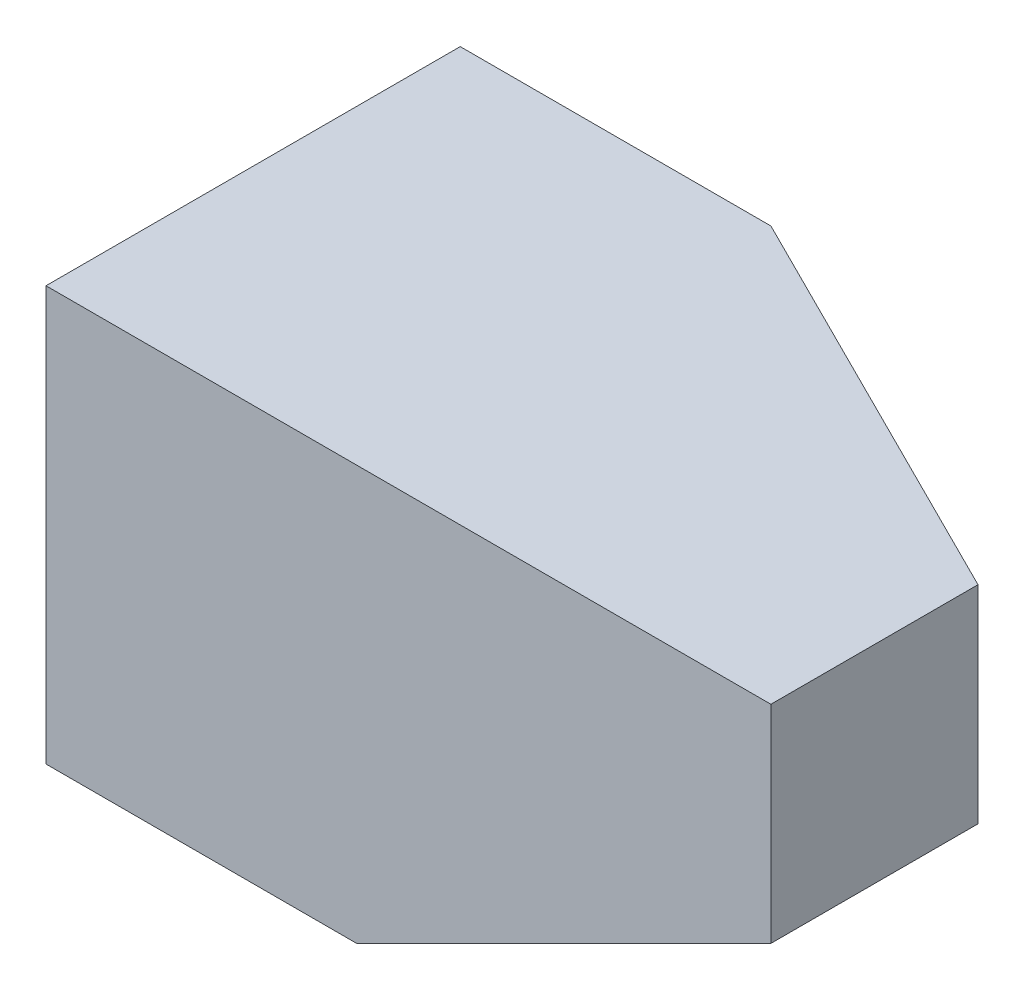
from build123d import *

# Parameters (mm, degrees)
SKETCH_1_W          = 70
SKETCH_1_H          = 40
EXTRUDE_1_DEPTH     = 40
CUT_EXTRUDE_1_DEPTH = 41
SKETCH_3_W          = 40
SKETCH_3_H          = 20
CUT_EXTRUDE_2_DEPTH = 20
CUT_EXTRUDE_3_DEPTH = 20
CUT_EXTRUDE_4_DEPTH = 31


with BuildPart() as part:
    # 草圖1 → 填料-伸長1 (new body)
    with BuildSketch(Plane(origin=(0, 0, 0), x_dir=(1, 0, 0), z_dir=(0, 1, 0))):
        with Locations((5, 0)):
            Rectangle(SKETCH_1_W, SKETCH_1_H)
    extrude(amount=EXTRUDE_1_DEPTH)

    # 草圖2 → 除料-伸長1 (cut, through all)
    with BuildSketch(Plane.XZ):
        Polygon((40, 0), (0, -20), (40, -20), align=None)
    extrude(amount=-CUT_EXTRUDE_1_DEPTH, mode=Mode.SUBTRACT)

    # 草圖3 → 除料-伸長2 (cut)
    with BuildSketch(Plane.XY):
        with Locations((20, 10)):
            Rectangle(SKETCH_3_W, SKETCH_3_H)
    extrude(amount=-CUT_EXTRUDE_2_DEPTH, mode=Mode.SUBTRACT)

    # 草圖4 → 除料-伸長3 (cut)
    with BuildSketch(Plane(origin=(0, 0, 0), x_dir=(-1, 0, 0), z_dir=(0, 0, -1))):
        Polygon((0, 0), (-40, 20), (-40, 0), align=None)
    extrude(amount=-CUT_EXTRUDE_3_DEPTH, mode=Mode.SUBTRACT)

    # 草圖5 → 除料-伸長4 (cut, through all)
    with BuildSketch(Plane(origin=(0, 0, 0), x_dir=(0, 0, -1), z_dir=(1, 0, 0))):
        Polygon((0, 0), (20, 20), (20, 0), align=None)
    extrude(amount=-CUT_EXTRUDE_4_DEPTH, mode=Mode.SUBTRACT)


solid = part.part
